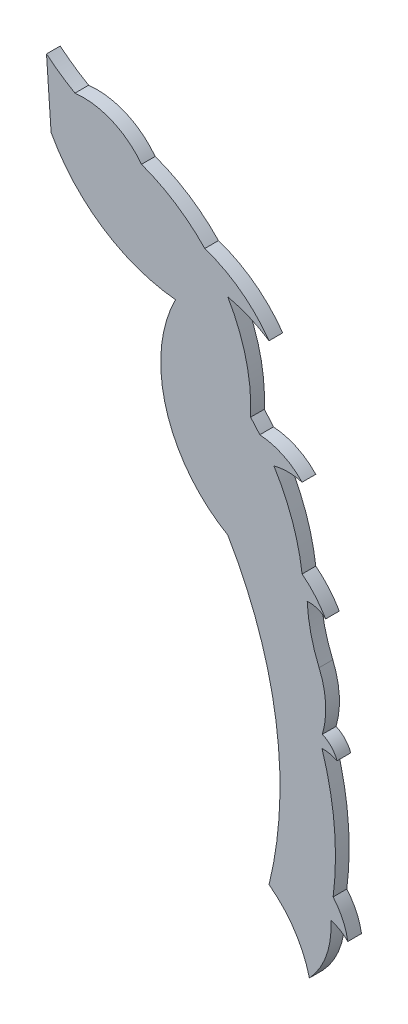
from build123d import *

# Parameters (mm, degrees)
BOSS_EXTRUDE1_DEPTH = 1.524


with BuildPart() as part:
    # Sketch1 → Boss-Extrude1 (new body)
    with BuildSketch(Plane.XY):
        with BuildLine():
            Line((-31.115654525, 85.743001786), (-31.626029854, 93.062039695))
            ThreePointArc((-31.626029854, 93.062039695), (-30.088685306, 91.89525557), (-28.45677625, 90.864873946))
            ThreePointArc((-28.45677625, 90.864873946), (-24.332080512, 90.260671192), (-21.042280839, 87.700320822))
            ThreePointArc((-21.042280839, 87.700320822), (-17.253316375, 85.808122938), (-13.994450183, 83.103228173))
            ThreePointArc((-13.994450183, 83.103228173), (-9.99101498, 81.01245123), (-6.834531764, 77.782055688))
            ThreePointArc((-6.834531764, 77.782055688), (-9.047280649, 78.959528297), (-11.434463645, 79.723764333))
            ThreePointArc((-11.434463645, 79.723764333), (-9.401311851, 74.738116942), (-8.891074145, 69.378075561))
            ThreePointArc((-8.891074145, 69.378075561), (-8.368327541, 68.796388825), (-7.866530285, 68.196536356))
            ThreePointArc((-7.866530285, 68.196536356), (-5.298466146, 67.533161121), (-3.150709885, 65.976831091))
            ThreePointArc((-3.150709885, 65.976831091), (-4.721037121, 66.188066002), (-6.291364357, 65.976831091))
            ThreePointArc((-6.291364357, 65.976831091), (-4.243849878, 61.717361935), (-3.150709885, 57.119488733))
            ThreePointArc((-3.150709885, 57.119488733), (-1.695723101, 55.731011208), (-0.531968435, 54.090727251))
            ThreePointArc((-0.531968435, 54.090727251), (-1.486021988, 54.647848886), (-2.584432422, 54.76658058))
            ThreePointArc((-2.584432422, 54.76658058), (-2.443936558, 53.294197652), (-2.174566125, 51.839862702))
            ThreePointArc((-2.174566125, 51.839862702), (-1.778406294, 50.414833592), (-1.258523697, 49.030141329))
            ThreePointArc((-1.258523697, 49.030141329), (-0.531968435, 45.93780464), (-0.893428223, 42.781893428))
            ThreePointArc((-0.893428223, 42.781893428), (0.100022048, 42.0811278), (0.742668626, 41.049129115))
            ThreePointArc((0.742668626, 41.049129115), (-0.079058418, 41.323600355), (-0.941146572, 41.409471254))
            ThreePointArc((-0.941146572, 41.409471254), (0.437078702, 34.619334125), (0.303865798, 27.692017078))
            ThreePointArc((0.303865798, 27.692017078), (1.362217268, 26.063134365), (1.940723645, 24.208761938))
            ThreePointArc((1.940723645, 24.208761938), (1.068913801, 24.887622398), (0.048705917, 25.311980504))
            ThreePointArc((0.048705917, 25.311980504), (-0.439629904, 21.681833995), (-2.339389119, 18.550165034))
            ThreePointArc((-2.339389119, 18.550165034), (-3.997880754, 22.322683164), (-6.834531764, 25.311980504))
            ThreePointArc((-6.834531764, 25.311980504), (-6.056862602, 41.475358139), (-11.434463645, 56.737761388))
            ThreePointArc((-11.434463645, 56.737761388), (-18.290136293, 65.474182448), (-17.253316375, 76.530868427))
            ThreePointArc((-17.253316375, 76.530868427), (-25.334641834, 79.406189783), (-31.115654525, 85.743001786))
        make_face()
    extrude(amount=BOSS_EXTRUDE1_DEPTH)


solid = part.part
